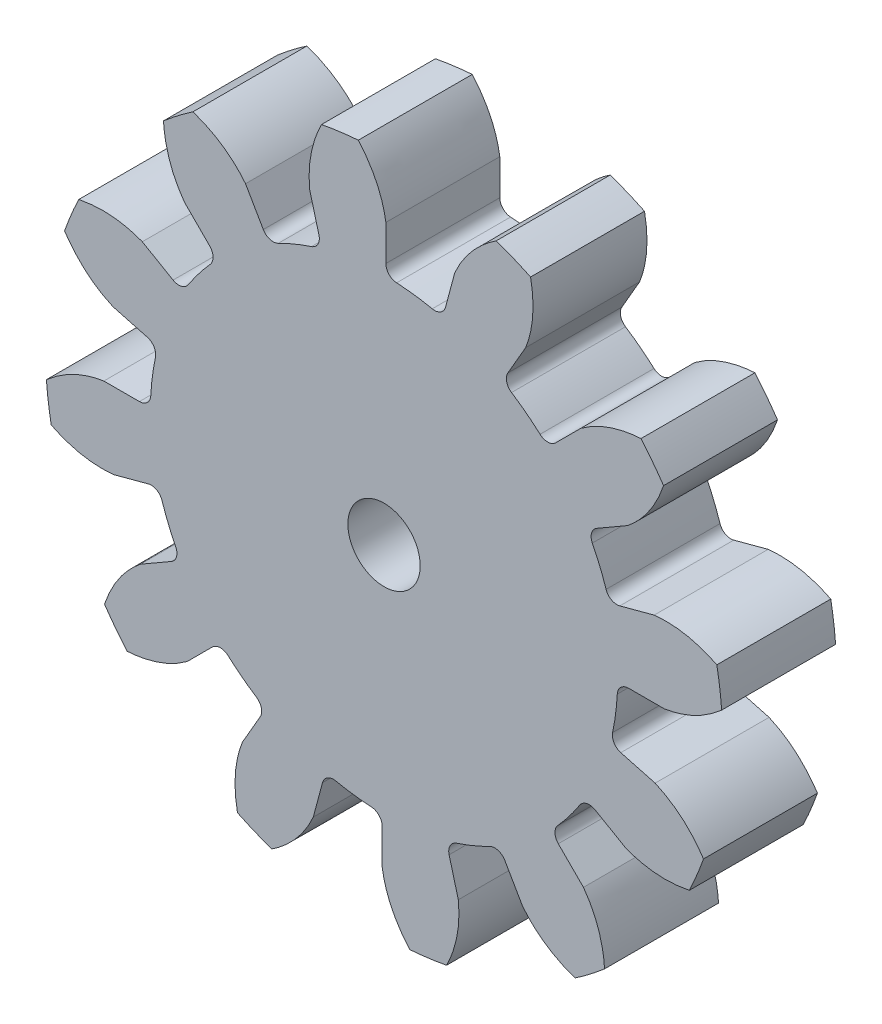
from build123d import *

# Parameters (mm, degrees)
SKETCH1_R                = 14.859
BOSS_EXTRUDE1_DEPTH      = 5
CUT_EXTRUDE1_DEPTH       = 6
FILLET1_R                = 0.498729
CIRPATTERN1_COUNT        = 12
FILLET1_OF_CIRPATTERN1_R = 0.498729
SKETCH5_R                = 1.5875
CUT_EXTRUDE2_DEPTH       = 6.0000049


with BuildPart() as part:
    # Sketch1 → Boss-Extrude1 (new body)
    with BuildSketch(Plane.XY):
        Circle(SKETCH1_R)
    extrude(amount=-BOSS_EXTRUDE1_DEPTH)

    # Sketch4 → Cut-Extrude1 (cut, through all)
    with BuildSketch(Plane.XY):
        with BuildLine():
            Line((0.080131787, 12.295213914), (0.080131787, 10.250703468))
            ThreePointArc((0.080131787, 10.250703468), (1.338029283, 10.163317388), (2.575681995, 9.922157274))
            Line((2.575681995, 9.922157274), (3.104841445, 11.897002391))
            add(Edge.make_bspline(
                [(5.071151281, 14.112882844), (3.70540161, 13.261726884), (3.104841445, 11.897002391)],
                knots=[0, 0, 0, 1, 1, 1], degree=2))
            ThreePointArc((5.071151281, 14.112882844), (1.957418943, 14.868037818), (-1.245663981, 14.944509317))
            add(Edge.make_bspline(
                [(-1.245663981, 14.944509317), (-0.146747194, 13.768873094), (0.080131787, 12.295213914)],
                knots=[0, 0, 0, 1, 1, 1], degree=2))
        make_face()
    cut_extrude1 = extrude(amount=-CUT_EXTRUDE1_DEPTH, mode=Mode.SUBTRACT)

    # Fillet1
    fillet1_edges = [part.edges().sort_by_distance(p)[0] for p in [
        (2.575681995, 9.922157274, -2.5),
        (0.080131787, 10.250703468, -2.5),
    ]]
    fillet(fillet1_edges, radius=FILLET1_R)

    # CirPattern1: Cut-Extrude1 ×12 about axis
    cirpattern1_axis = Axis((0, 0, -5), (0, 0, 1))
    for i in range(1, CIRPATTERN1_COUNT):
        add(cut_extrude1.rotate(cirpattern1_axis, i * 360 / CIRPATTERN1_COUNT), mode=Mode.SUBTRACT)

    # Fillet1 of CirPattern1
    fillet1_of_cirpattern1_edges = [part.edges().sort_by_distance(p)[0] for p in [
        (-2.730472597, 9.880681257, -2.5),
        (-5.055955571, 8.917435504, -2.5),
        (-7.304999262, 7.191684677, -2.5),
        (-8.837303717, 5.194747897, -2.5),
        (-9.922157274, 2.575681995, -2.5),
        (-10.250703468, 0.080131787, -2.5),
        (-9.880681257, -2.730472597, -2.5),
        (-8.917435504, -5.055955571, -2.5),
        (-7.191684677, -7.304999262, -2.5),
        (-5.194747897, -8.837303717, -2.5),
        (-2.575681995, -9.922157274, -2.5),
        (-0.080131787, -10.250703468, -2.5),
        (2.730472597, -9.880681257, -2.5),
        (5.055955571, -8.917435504, -2.5),
        (7.304999262, -7.191684677, -2.5),
        (8.837303717, -5.194747897, -2.5),
        (9.922157274, -2.575681995, -2.5),
        (10.250703468, -0.080131787, -2.5),
        (9.880681257, 2.730472597, -2.5),
        (8.917435504, 5.055955571, -2.5),
        (7.191684677, 7.304999262, -2.5),
        (5.194747897, 8.837303717, -2.5),
    ]]
    fillet(fillet1_of_cirpattern1_edges, radius=FILLET1_OF_CIRPATTERN1_R)

    # Sketch5 → Cut-Extrude2 (cut, through all)
    with BuildSketch(Plane.XY):
        Circle(SKETCH5_R)
    extrude(amount=-CUT_EXTRUDE2_DEPTH, mode=Mode.SUBTRACT)


solid = part.part
